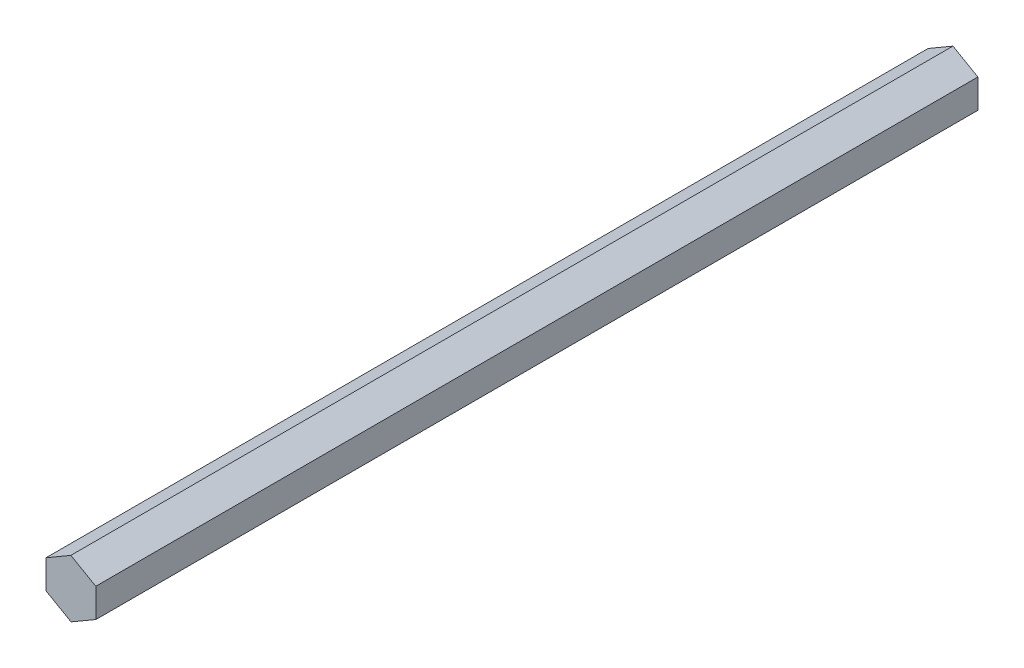
from build123d import *

# Parameters (mm, degrees)
BOSS_EXTRUDE1_DEPTH = 225


with BuildPart() as part:
    # Sketch1 → Boss-Extrude1 (new body)
    with BuildSketch(Plane.XY):
        Polygon((6.333806227, 3.694080672), (-0.032264592, 7.332277431), (-6.366070819, 3.638196759), (-6.333806227, -3.694080672), (0.032264592, -7.332277431), (6.366070819, -3.638196759), align=None)
    extrude(amount=BOSS_EXTRUDE1_DEPTH)


solid = part.part
